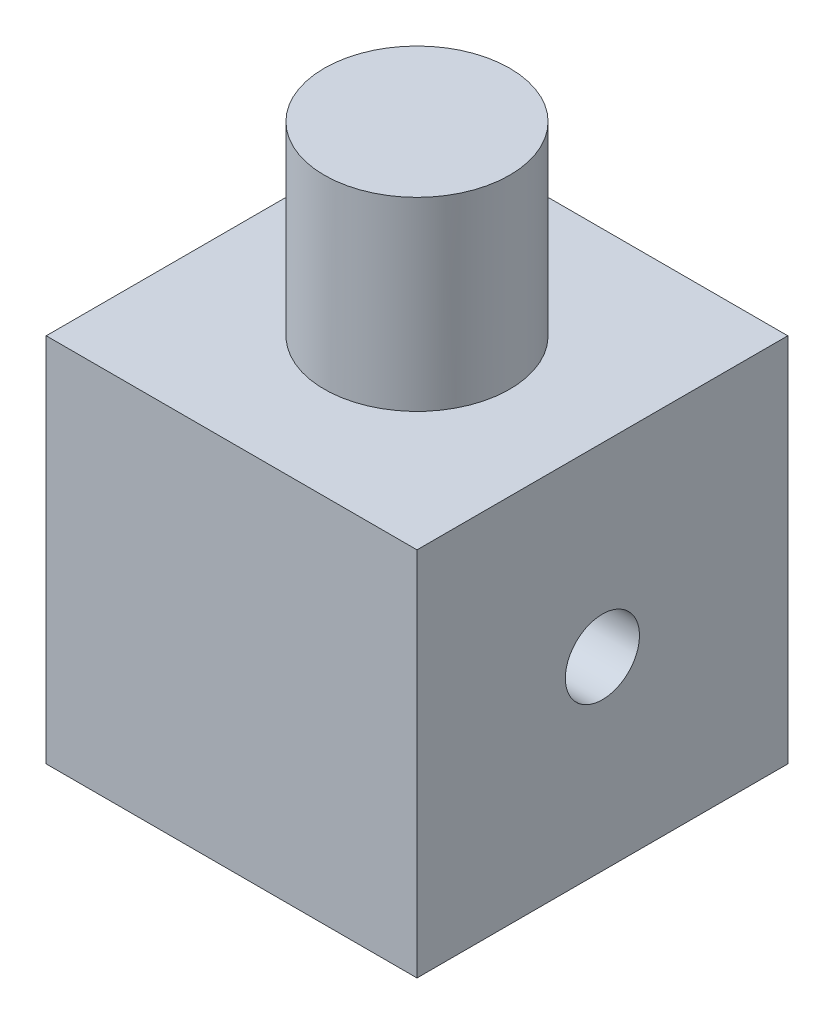
from build123d import *

# Parameters (mm, degrees)
SKETCH1_W           = 10
SKETCH1_H           = 10
BOSS_EXTRUDE1_DEPTH = 10
SKETCH2_R           = 2.5
BOSS_EXTRUDE2_DEPTH = 5
SKETCH3_R           = 1
CUT_EXTRUDE1_DEPTH  = 10
SKETCH4_R           = 0.5
CUT_EXTRUDE2_DEPTH  = 5


with BuildPart() as part:
    # Sketch1 → Boss-Extrude1 (new body)
    with BuildSketch(Plane(origin=(0, 0, 0), x_dir=(1, 0, 0), z_dir=(0, 1, 0))):
        with Locations((-9.64819331, 21.790774606)):
            Rectangle(SKETCH1_W, SKETCH1_H)
    extrude(amount=BOSS_EXTRUDE1_DEPTH)

    # Sketch2 → Boss-Extrude2 (add)
    with BuildSketch(Plane(origin=(0, 10, 0), x_dir=(1, 0, 0), z_dir=(0, 1, 0))):
        with Locations((-9.64819331, 21.790774606)):
            Circle(SKETCH2_R)
    extrude(amount=BOSS_EXTRUDE2_DEPTH)

    # Sketch3 → Cut-Extrude1 (cut)
    with BuildSketch(Plane.ZY.offset(14.64819331)):
        with Locations((-21.790774606, 5)):
            Circle(SKETCH3_R)
    extrude(amount=-CUT_EXTRUDE1_DEPTH, mode=Mode.SUBTRACT)

    # Sketch4 → Cut-Extrude2 (cut)
    with BuildSketch(Plane(origin=(0, 0, 0), x_dir=(-1, 0, 0), z_dir=(0, -1, 0))):
        with Locations((9.64819331, 21.790774606)):
            Circle(SKETCH4_R)
    extrude(amount=-CUT_EXTRUDE2_DEPTH, mode=Mode.SUBTRACT)


solid = part.part
